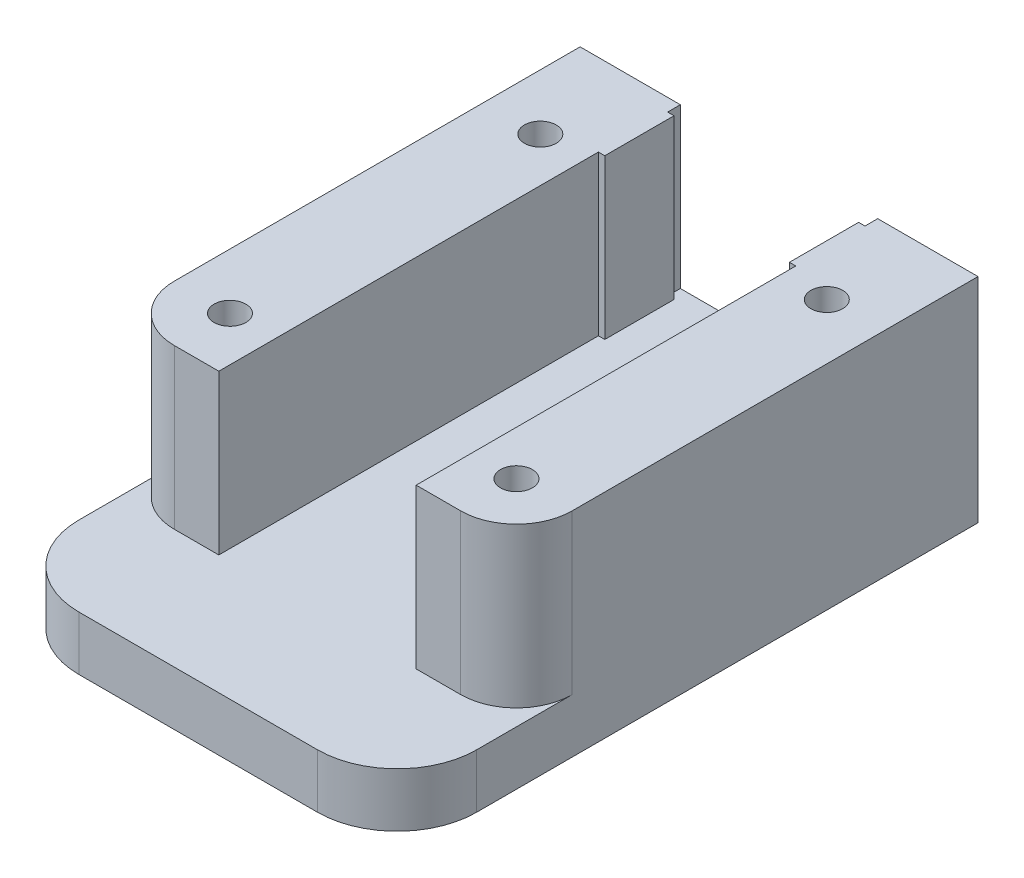
from build123d import *

# Parameters (mm, degrees)
SKETCH1_W           = 30
SKETCH1_H           = 12.5
BOSS_EXTRUDE1_DEPTH = 1.6
SKETCH2_W           = 25
SKETCH2_H           = 36.5
BOSS_EXTRUDE2_DEPTH = 3.4
SKETCH3_W           = 6.3
SKETCH3_H           = 30
BOSS_EXTRUDE3_DEPTH = 10
FILLET1_R           = 5
SKETCH4_R           = 1
CUT_EXTRUDE1_DEPTH  = 16
CUT_EXTRUDE2_DEPTH  = 10
SKETCH9_W           = 0.4
SKETCH9_H           = 4.35
BOSS_EXTRUDE4_DEPTH = 10
SKETCH10_R          = 1
CUT_EXTRUDE3_DEPTH  = 16
SKETCH11_W          = 36.216016417
SKETCH11_H          = 16.907618384
CUT_EXTRUDE4_DEPTH  = 1.6


with BuildPart() as part:
    # Sketch1 → Boss-Extrude1 (new body)
    with BuildSketch(Plane(origin=(0, 0, 0), x_dir=(1, 0, 0), z_dir=(0, 1, 0))):
        with Locations((0, -6.25)):
            Rectangle(SKETCH1_W, SKETCH1_H)
    extrude(amount=BOSS_EXTRUDE1_DEPTH)

    # Sketch2 → Boss-Extrude2 (add)
    with BuildSketch(Plane(origin=(0, 1.6, 0), x_dir=(1, 0, 0), z_dir=(0, 1, 0))):
        with Locations((0, -18.25)):
            Rectangle(SKETCH2_W, SKETCH2_H)
    extrude(amount=BOSS_EXTRUDE2_DEPTH)

    # Sketch3 → Boss-Extrude3 (add)
    with BuildSketch(Plane(origin=(0, 5, 0), x_dir=(1, 0, 0), z_dir=(0, 1, 0))):
        with Locations((-9.35, -15)):
            Rectangle(SKETCH3_W, SKETCH3_H)
        with Locations((9.35, -15)):
            Rectangle(SKETCH3_W, SKETCH3_H)
    extrude(amount=BOSS_EXTRUDE3_DEPTH)

    # Fillet1
    fillet1_edges = [part.edges().sort_by_distance(p)[0] for p in [
        (12.5, 3.3, 36.5),
        (-12.5, 3.3, 36.5),
    ]]
    fillet(fillet1_edges, radius=FILLET1_R)

    # Sketch4 → Cut-Extrude1 (cut, through all)
    with BuildSketch(Plane(origin=(0, 15, 0), x_dir=(1, 0, 0), z_dir=(0, 1, 0))):
        with Locations((-9, -25.5)):
            Circle(SKETCH4_R)
        with Locations((9, -25.5)):
            Circle(SKETCH4_R)
    extrude(amount=-CUT_EXTRUDE1_DEPTH, mode=Mode.SUBTRACT)

    # Sketch5 → Cut-Extrude2 (cut)
    with BuildSketch(Plane(origin=(0, 15, 0), x_dir=(1, 0, 0), z_dir=(0, 1, 0))):
        with BuildLine():
            Line((-9, -29), (9, -29))
            ThreePointArc((9, -29), (11.474873734, -27.974873734), (12.5, -25.5))
            Line((12.5, -25.5), (17.216027855, -25.5))
            Line((17.216027855, -25.5), (17.216027855, -35.629206005))
            Line((17.216027855, -35.629206005), (-17.65496497, -35.320310993))
            Line((-17.65496497, -35.320310993), (-17.65496497, -25.5))
            Line((-17.65496497, -25.5), (-12.5, -25.5))
            ThreePointArc((-12.5, -25.5), (-11.474873734, -27.974873734), (-9, -29))
        make_face()
    extrude(amount=-CUT_EXTRUDE2_DEPTH, mode=Mode.SUBTRACT)

    # Sketch9 → Boss-Extrude4 (add)
    with BuildSketch(Plane(origin=(0, 5, 0), x_dir=(1, 0, 0), z_dir=(0, 1, 0))):
        with Locations((-6, -2.975)):
            Rectangle(SKETCH9_W, SKETCH9_H)
        with Locations((6, -2.975)):
            Rectangle(SKETCH9_W, SKETCH9_H)
    extrude(amount=BOSS_EXTRUDE4_DEPTH)

    # Sketch10 → Cut-Extrude3 (cut, through all)
    with BuildSketch(Plane(origin=(0, 15, 0), x_dir=(1, 0, 0), z_dir=(0, 1, 0))):
        with Locations((-9, -6)):
            Circle(SKETCH10_R)
        with Locations((9, -6)):
            Circle(SKETCH10_R)
    extrude(amount=-CUT_EXTRUDE3_DEPTH, mode=Mode.SUBTRACT)

    # Sketch11 → Cut-Extrude4 (cut)
    with BuildSketch(Plane.XZ):
        with Locations((-0.332022718, 6.399318006)):
            Rectangle(SKETCH11_W, SKETCH11_H)
    extrude(amount=-CUT_EXTRUDE4_DEPTH, mode=Mode.SUBTRACT)


solid = part.part
